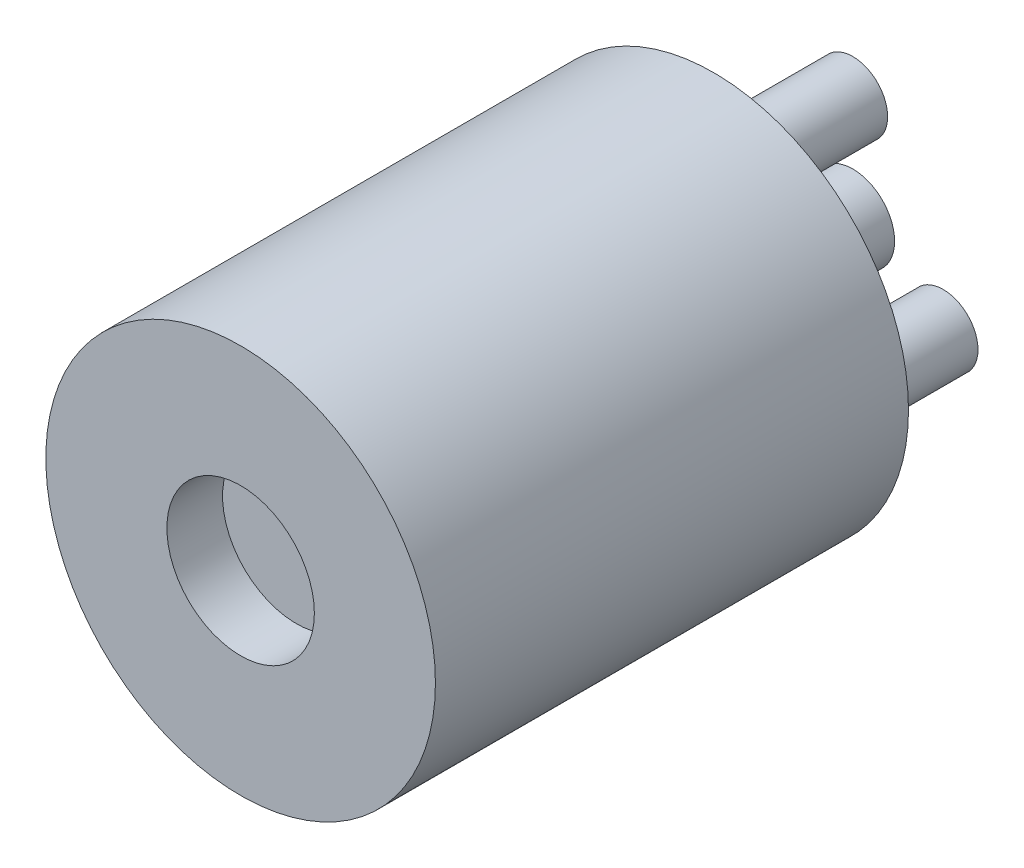
from build123d import *

# Parameters (mm, degrees)
SKETCH1_R           = 7
SKETCH1_R_2         = 1.25
BOSS_EXTRUDE1_DEPTH = 17
SKETCH2_R           = 7
BOSS_EXTRUDE2_DEPTH = 11
SKETCH3_R           = 2.65
CUT_EXTRUDE1_DEPTH  = 2
SKETCH4_R           = 1.5
BOSS_EXTRUDE3_DEPTH = 5
SKETCH5_R           = 1.25
BOSS_EXTRUDE4_DEPTH = 5
SKETCH6_R           = 7
BOSS_EXTRUDE5_DEPTH = 15


with BuildPart() as part:
    # Sketch1 → Boss-Extrude1 (new body)
    with BuildSketch(Plane.XY):
        with Locations((-43.483141232, -69.989052064)):
            Circle(SKETCH1_R)
        with Locations((-43.483141232, -66.239052064)):
            Circle(SKETCH1_R_2, mode=Mode.SUBTRACT)
        with Locations((-40.235545968, -71.864052064)):
            Circle(SKETCH1_R_2, mode=Mode.SUBTRACT)
        with Locations((-46.730736496, -71.864052064)):
            Circle(SKETCH1_R_2, mode=Mode.SUBTRACT)
    extrude(amount=BOSS_EXTRUDE1_DEPTH)

    # Sketch2 → Boss-Extrude2 (add)
    with BuildSketch(Plane.XY.offset(17)):
        with Locations((-43.483141232, -69.989052064)):
            Circle(SKETCH2_R)
    extrude(amount=-BOSS_EXTRUDE2_DEPTH)

    # Sketch3 → Cut-Extrude1 (cut)
    with BuildSketch(Plane.XY.offset(17)):
        with Locations((-43.483141232, -69.989052064)):
            Circle(SKETCH3_R)
    extrude(amount=-CUT_EXTRUDE1_DEPTH, mode=Mode.SUBTRACT)

    # Sketch4 → Boss-Extrude3 (add)
    with BuildSketch(Plane(origin=(0, 0, 0), x_dir=(-1, 0, 0), z_dir=(0, 0, -1))):
        with Locations((43.483141232, -69.989052064)):
            Circle(SKETCH4_R)
    extrude(amount=BOSS_EXTRUDE3_DEPTH)

    # Sketch5 → Boss-Extrude4 (add, symmetric)
    with BuildSketch(Plane(origin=(0, 0, 0), x_dir=(-1, 0, 0), z_dir=(0, 0, -1))):
        with Locations((43.483141232, -66.239052064)):
            Circle(SKETCH5_R)
        with Locations((46.730736496, -71.864052064)):
            Circle(SKETCH5_R)
        with Locations((40.235545968, -71.864052064)):
            Circle(SKETCH5_R)
    extrude(amount=BOSS_EXTRUDE4_DEPTH, both=True)

    # Sketch6 → Boss-Extrude5 (add)
    with BuildSketch(Plane(origin=(0, 0, 0), x_dir=(-1, 0, 0), z_dir=(0, 0, -1))):
        with Locations((43.483141232, -69.989052064)):
            Circle(SKETCH6_R)
    extrude(amount=-BOSS_EXTRUDE5_DEPTH)


solid = part.part
